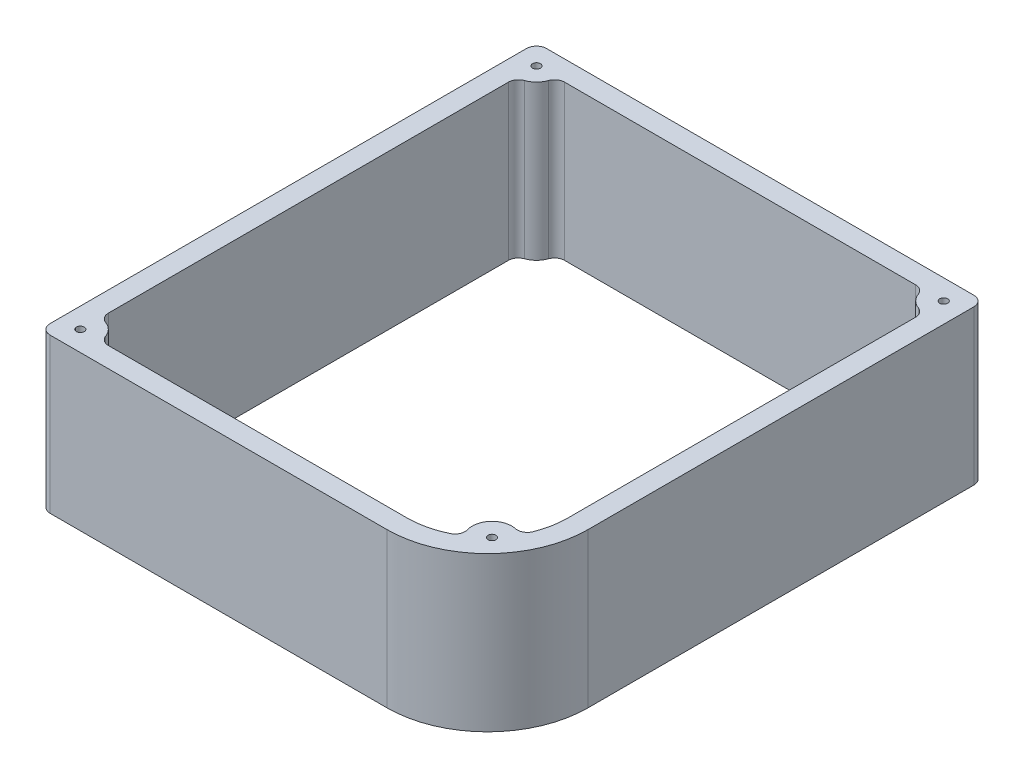
from build123d import *

# Parameters (mm, degrees)
SKETCH1_R           = 1
BOSS_EXTRUDE3_DEPTH = 39
FILLET1_R           = 2.54


with BuildPart() as part:
    # Sketch1 → Boss-Extrude3 (new body)
    with BuildSketch(Plane(origin=(0, 0, 0), x_dir=(1, 0, 0), z_dir=(0, 1, 0))):
        with BuildLine():
            Line((48.284490735, 53.109977813), (-64.735509285, 53.109977813))
            Line((-64.735509285, 53.109977813), (-64.735509285, -72.290076187))
            Line((-64.735509285, -72.290076187), (22.884490735, -72.290076187))
            ThreePointArc((22.884490735, -72.290076187), (40.845002977, -64.850588429), (48.284490735, -46.890076187))
            Line((48.284490735, -46.890076187), (48.284490735, 53.109977813))
        make_face()
        with Locations((-59.655509285, 48.029977813)):
            Circle(SKETCH1_R, mode=Mode.SUBTRACT)
        with Locations((43.204490735, 48.029977813)):
            Circle(SKETCH1_R, mode=Mode.SUBTRACT)
        with Locations((-59.655509285, -67.210076187)):
            Circle(SKETCH1_R, mode=Mode.SUBTRACT)
        with Locations((37.880892571, -60.748479124)):
            Circle(SKETCH1_R, mode=Mode.SUBTRACT)
        with BuildLine():
            Line((38.204490735, 48.029977813), (-54.655509285, 48.029977813))
            ThreePointArc((-54.655509285, 48.029977813), (-56.119975379, 44.494443907), (-59.655509285, 43.029977813))
            Line((-59.655509285, 43.029977813), (-59.655509285, -62.210076187))
            ThreePointArc((-59.655509285, -62.210076187), (-56.119975379, -63.674542281), (-54.655509285, -67.210076187))
            Line((-54.655509285, -67.210076187), (22.884490735, -67.210076187))
            ThreePointArc((22.884490735, -67.210076187), (28.683169352, -66.365130135), (33.999606769, -63.900561058))
            ThreePointArc((33.999606769, -63.900561058), (34.208776178, -57.355020535), (40.717513048, -56.63100608))
            ThreePointArc((40.717513048, -56.63100608), (42.572931676, -51.916774238), (43.204490735, -46.890076187))
            Line((43.204490735, -46.890076187), (43.204490735, 43.029977813))
            ThreePointArc((43.204490735, 43.029977813), (39.668956829, 44.494443907), (38.204490735, 48.029977813))
        make_face(mode=Mode.SUBTRACT)
    extrude(amount=BOSS_EXTRUDE3_DEPTH)

    # Fillet1
    fillet1_edges = [part.edges().sort_by_distance(p)[0] for p in [
        (33.999606769, 19.5, 63.900561058),
        (40.717513048, 19.5, 56.63100608),
        (43.204490735, 19.5, -43.029977813),
        (38.204490735, 19.5, -48.029977813),
        (-54.655509285, 19.5, -48.029977813),
        (-59.655509285, 19.5, -43.029977813),
        (-59.655509285, 19.5, 62.210076187),
        (-54.655509285, 19.5, 67.210076187),
        (-64.735509285, 19.5, 72.290076187),
        (-64.735509285, 19.5, -53.109977813),
        (48.284490735, 19.5, -53.109977813),
    ]]
    fillet(fillet1_edges, radius=FILLET1_R)


solid = part.part
